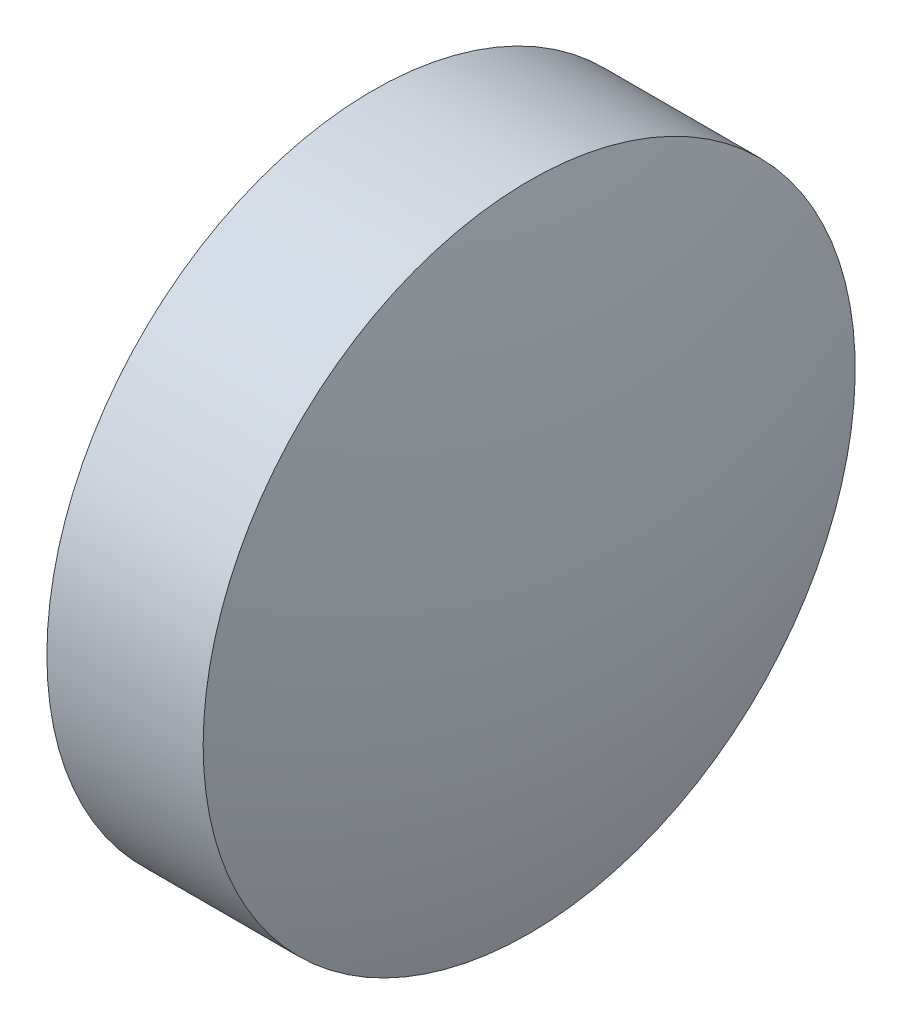
from build123d import *


with BuildPart() as part:
    # 草图1 → 旋转1 (revolve)
    with BuildSketch(Plane.XY, mode=Mode.PRIVATE) as revolve_1_sk:
        with BuildLine():
            Line((607.081648003, -17.201183962), (607.081648003, -14.051183962))
            Line((607.081648003, -14.051183962), (608.591648003, -14.051183962))
            ThreePointArc((608.591648003, -14.051183962), (608.958415786, -15.607242307), (609.081648003, -17.201183962))
            Line((609.081648003, -17.201183962), (607.081648003, -17.201183962))
        make_face()
    revolve(revolve_1_sk.sketch.rotate(Axis((606.27593759, -17.201183962, 0), (1, 0, 0)), 180), axis=Axis((606.27593759, -17.201183962, 0), (1, 0, 0)))  # turned: the seam where the file's is


solid = part.part
